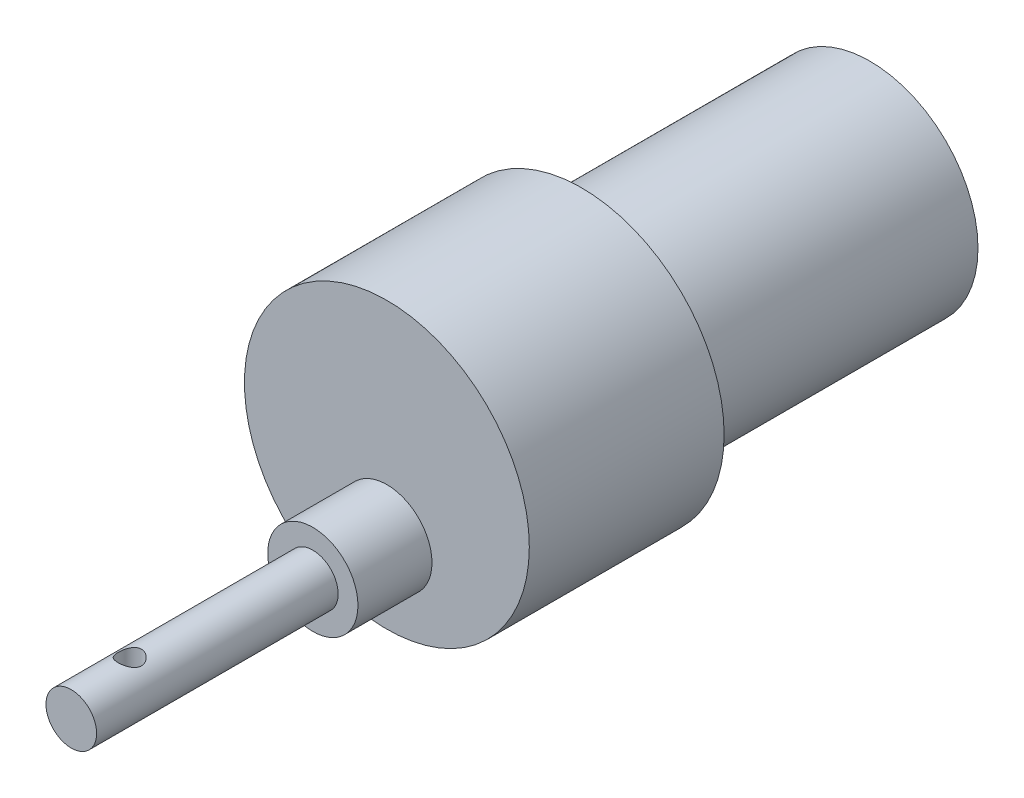
from build123d import *

# Parameters (mm, degrees)
SKETCH6_R           = 13.86
BOSS_EXTRUDE4_DEPTH = 62
SKETCH7_R           = 18.28
BOSS_EXTRUDE5_DEPTH = 25
SKETCH8_R           = 5.79
BOSS_EXTRUDE6_DEPTH = 9.5
SKETCH9_R           = 3.25
BOSS_EXTRUDE7_DEPTH = 31
SKETCH13_R          = 1.5
CUT_EXTRUDE1_DEPTH  = 20


with BuildPart() as part:
    # Sketch6 → Boss-Extrude4 (new body)
    with BuildSketch(Plane.XY):
        Circle(SKETCH6_R)
    extrude(amount=BOSS_EXTRUDE4_DEPTH)

    # Sketch7 → Boss-Extrude5 (add)
    with BuildSketch(Plane.XY.offset(37)):
        Circle(SKETCH7_R)
    extrude(amount=BOSS_EXTRUDE5_DEPTH)

    # Sketch8 → Boss-Extrude6 (add)
    with BuildSketch(Plane.XY.offset(62)):
        with Locations((0, -7.99)):
            Circle(SKETCH8_R)
    extrude(amount=BOSS_EXTRUDE6_DEPTH)

    # Sketch9 → Boss-Extrude7 (add)
    with BuildSketch(Plane.XY.offset(71.5)):
        with Locations((0, -7.99)):
            Circle(SKETCH9_R)
    extrude(amount=BOSS_EXTRUDE7_DEPTH)

    # Sketch13 → Cut-Extrude1 (cut)
    with BuildSketch(Plane(origin=(0, 0, 0), x_dir=(1, 0, 0), z_dir=(0, 1, 0))):
        with Locations((0, -95)):
            Circle(SKETCH13_R)
    extrude(amount=-CUT_EXTRUDE1_DEPTH, mode=Mode.SUBTRACT)


solid = part.part
